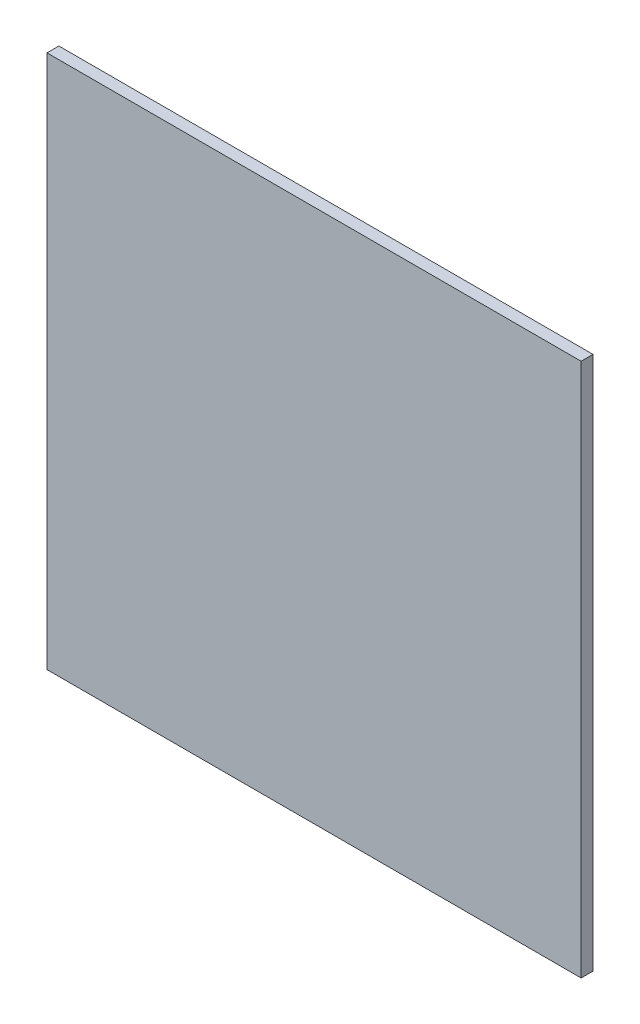
from build123d import *

# Parameters (mm, degrees)
SKETCH_1_W      = 45
SKETCH_1_H      = 45
EXTRUDE_1_DEPTH = 1


with BuildPart() as part:
    # Эскиз1 → Бобышка-Вытянуть1 (new body)
    with BuildSketch(Plane.XY):
        Rectangle(SKETCH_1_W, SKETCH_1_H)
    extrude(amount=EXTRUDE_1_DEPTH)


solid = part.part
